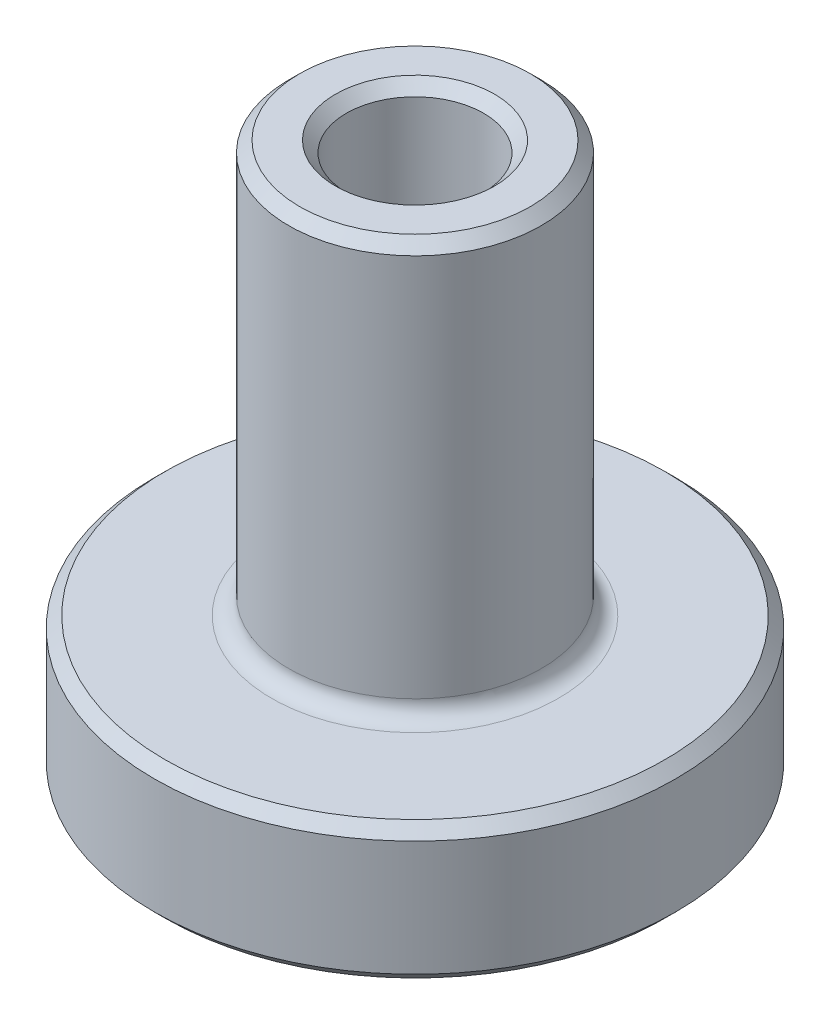
from build123d import *

# Parameters (mm, degrees)
FILLET1_R     = 0.396875
CHAMFER1_SIZE = 0.254


with BuildPart() as part:
    # Sketch1 → Revolve1 (revolve)
    with BuildSketch(Plane.XY):
        Polygon((1.5875, 0), (6.0325, 0), (6.0325, 3.175), (2.921, 3.175), (2.921, 12.7), (1.5875, 12.7), align=None)
    revolve(axis=Axis((0, 7.886499903, 0), (0, -1, 0)))

    # Fillet1
    fillet1_edges = [part.edges().sort_by_distance(p)[0] for p in [
        (-2.921, 3.175, 0),
    ]]
    fillet(fillet1_edges, radius=FILLET1_R)

    # Chamfer1
    chamfer1_edges = [part.edges().sort_by_distance(p)[0] for p in [
        (-1.5875, 12.7, 0),
        (-2.921, 12.7, 0),
        (-6.0325, 3.175, 0),
        (-6.0325, 0, 0),
        (-1.5875, 0, 0),
    ]]
    chamfer(chamfer1_edges, length=CHAMFER1_SIZE)


solid = part.part
